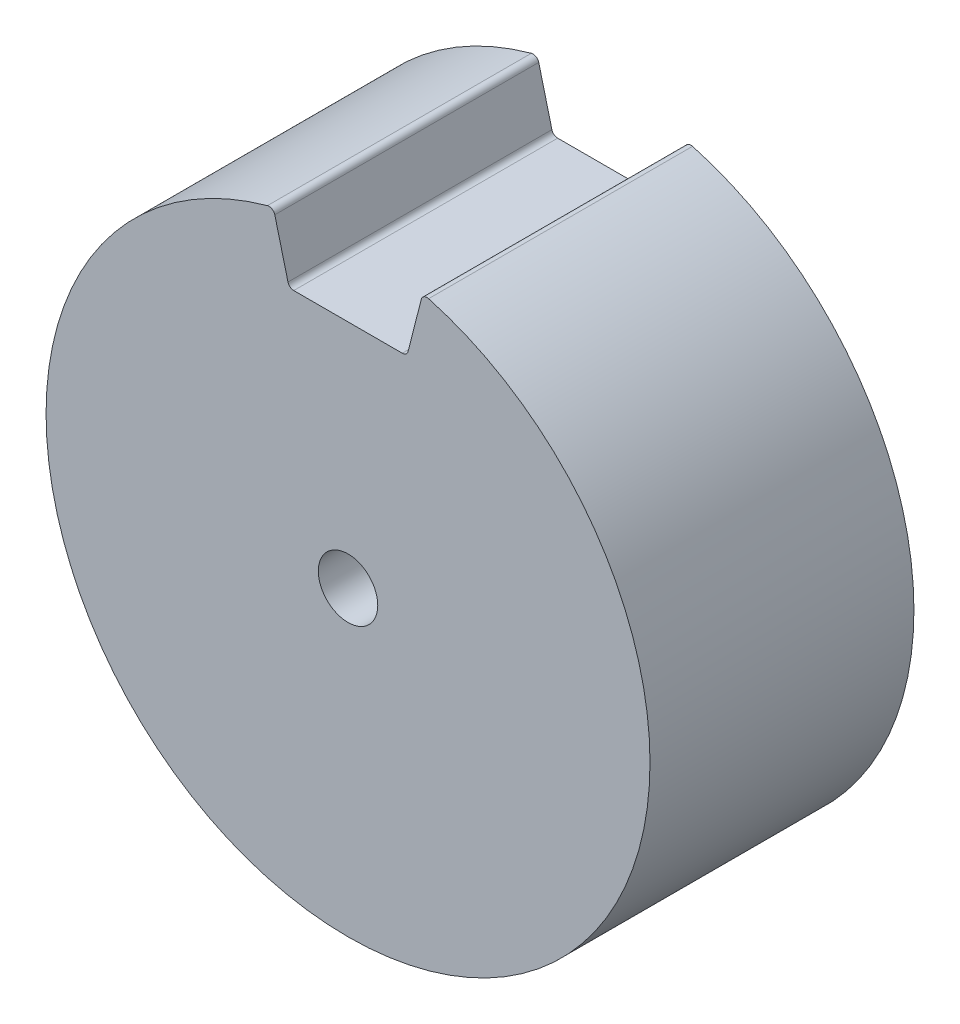
from build123d import *

# Parameters (mm, degrees)
SKETCH2_R           = 2.5
BOSS_EXTRUDE2_DEPTH = 22.2
FILLET1_R           = 0.5


with BuildPart() as part:
    # Sketch2 → Boss-Extrude2 (new body)
    with BuildSketch(Plane.XY):
        with BuildLine():
            Line((4.955, 19.4), (-4.955, 19.4))
            Line((-4.955, 19.4), (-6.285688199, 24.609959851))
            ThreePointArc((-6.285688199, 24.609959851), (-15.580492928, -20.060115656), (25.4, 0))
            ThreePointArc((25.4, 0), (20.060115656, 15.580492928), (6.285688199, 24.609959851))
            Line((6.285688199, 24.609959851), (4.955, 19.4))
        make_face()
        Circle(SKETCH2_R, mode=Mode.SUBTRACT)
    extrude(amount=BOSS_EXTRUDE2_DEPTH)

    # Fillet1
    fillet1_edges = [part.edges().sort_by_distance(p)[0] for p in [
        (-4.955, 19.4, 11.1),
        (4.955, 19.4, 11.1),
        (6.285688199, 24.609959851, 11.1),
        (-6.285688199, 24.609959851, 11.1),
    ]]
    fillet(fillet1_edges, radius=FILLET1_R)


solid = part.part
